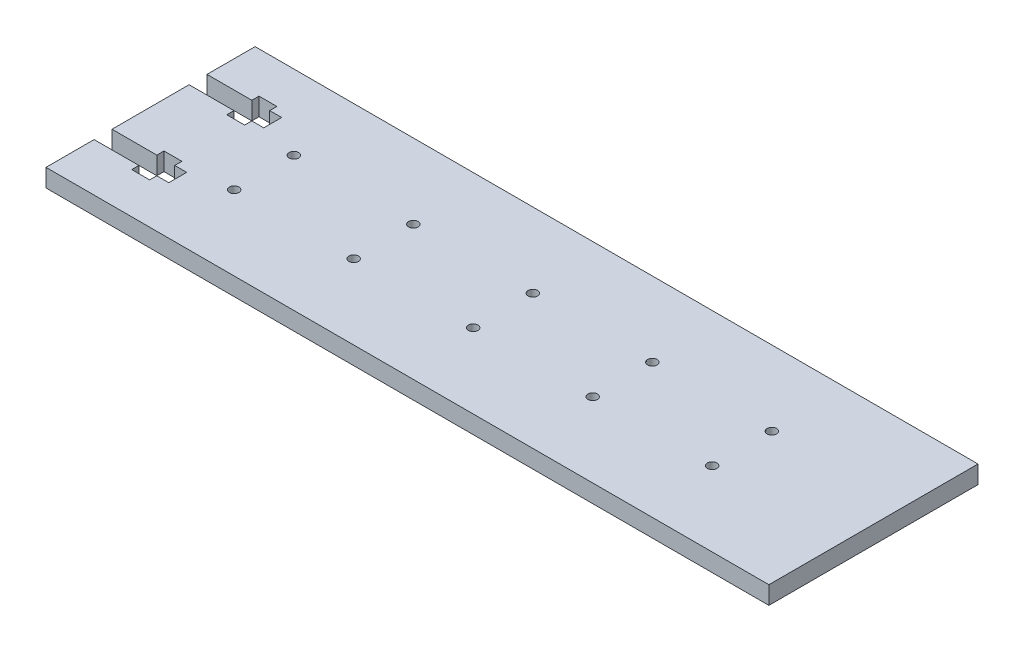
from build123d import *

# Parameters (mm, degrees)
SKETCH1_W           = 242
SKETCH1_H           = 70
SKETCH1_R           = 1.6
BOSS_EXTRUDE1_DEPTH = 6
CUT_EXTRUDE2_DEPTH  = 7


with BuildPart() as part:
    # Sketch1 → Boss-Extrude1 (new body)
    with BuildSketch(Plane(origin=(0, 0, 0), x_dir=(1, 0, 0), z_dir=(0, 1, 0))):
        Rectangle(SKETCH1_W, SKETCH1_H)
        with Locations((77, -10)):
            Circle(SKETCH1_R, mode=Mode.SUBTRACT)
        with Locations((77, 10)):
            Circle(SKETCH1_R, mode=Mode.SUBTRACT)
        with Locations((37, -10)):
            Circle(SKETCH1_R, mode=Mode.SUBTRACT)
        with Locations((37, 10)):
            Circle(SKETCH1_R, mode=Mode.SUBTRACT)
        with Locations((-3, -10)):
            Circle(SKETCH1_R, mode=Mode.SUBTRACT)
        with Locations((-3, 10)):
            Circle(SKETCH1_R, mode=Mode.SUBTRACT)
        with Locations((-43, -10)):
            Circle(SKETCH1_R, mode=Mode.SUBTRACT)
        with Locations((-43, 10)):
            Circle(SKETCH1_R, mode=Mode.SUBTRACT)
        with Locations((-83, -10)):
            Circle(SKETCH1_R, mode=Mode.SUBTRACT)
        with Locations((-83, 10)):
            Circle(SKETCH1_R, mode=Mode.SUBTRACT)
    extrude(amount=BOSS_EXTRUDE1_DEPTH)

    # Sketch3 → Cut-Extrude2 (cut, through all)
    with BuildSketch(Plane(origin=(0, 6, 0), x_dir=(1, 0, 0), z_dir=(0, 1, 0))):
        Polygon((-121, 12.9), (-106, 12.9), (-106, 10.5), (-100, 10.5), (-100, 12.9), (-96, 12.9), (-96, 18.9), (-100, 18.9), (-100, 21.3), (-106, 21.3), (-106, 18.9), (-121, 18.9), align=None)
        Polygon((-106, -18.9), (-106, -21.3), (-100, -21.3), (-100, -18.9), (-96, -18.9), (-96, -12.9), (-100, -12.9), (-100, -10.5), (-106, -10.5), (-106, -12.9), (-121, -12.9), (-121, -18.9), align=None)
    extrude(amount=-CUT_EXTRUDE2_DEPTH, mode=Mode.SUBTRACT)


solid = part.part
